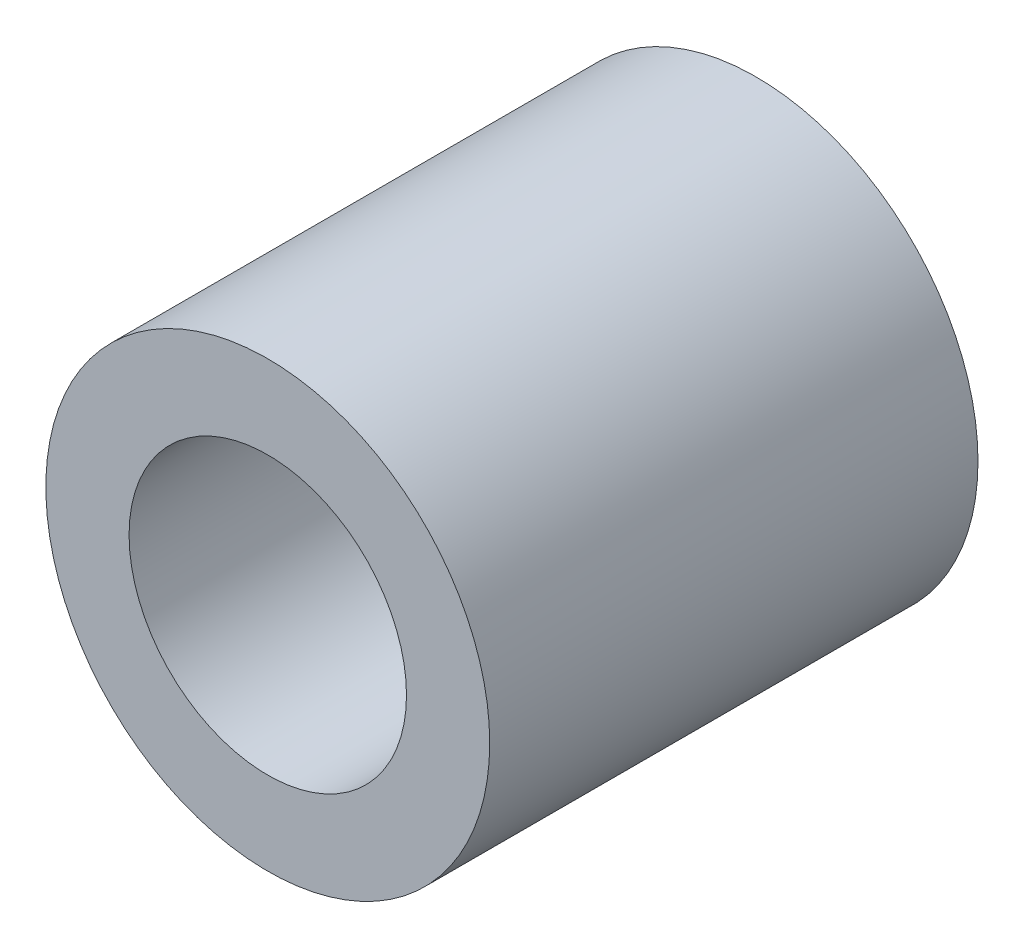
from build123d import *

# Parameters (mm, degrees)
SKETCH1_R           = 6.35
SKETCH1_R_2         = 3.96875
BOSS_EXTRUDE1_DEPTH = 13.97


with BuildPart() as part:
    # Sketch1 → Boss-Extrude1 (new body)
    with BuildSketch(Plane.XY):
        with Locations((-98.155981729, 22.86)):
            Circle(SKETCH1_R)
        with Locations((-98.155981729, 22.86)):
            Circle(SKETCH1_R_2, mode=Mode.SUBTRACT)
    extrude(amount=BOSS_EXTRUDE1_DEPTH)


solid = part.part
